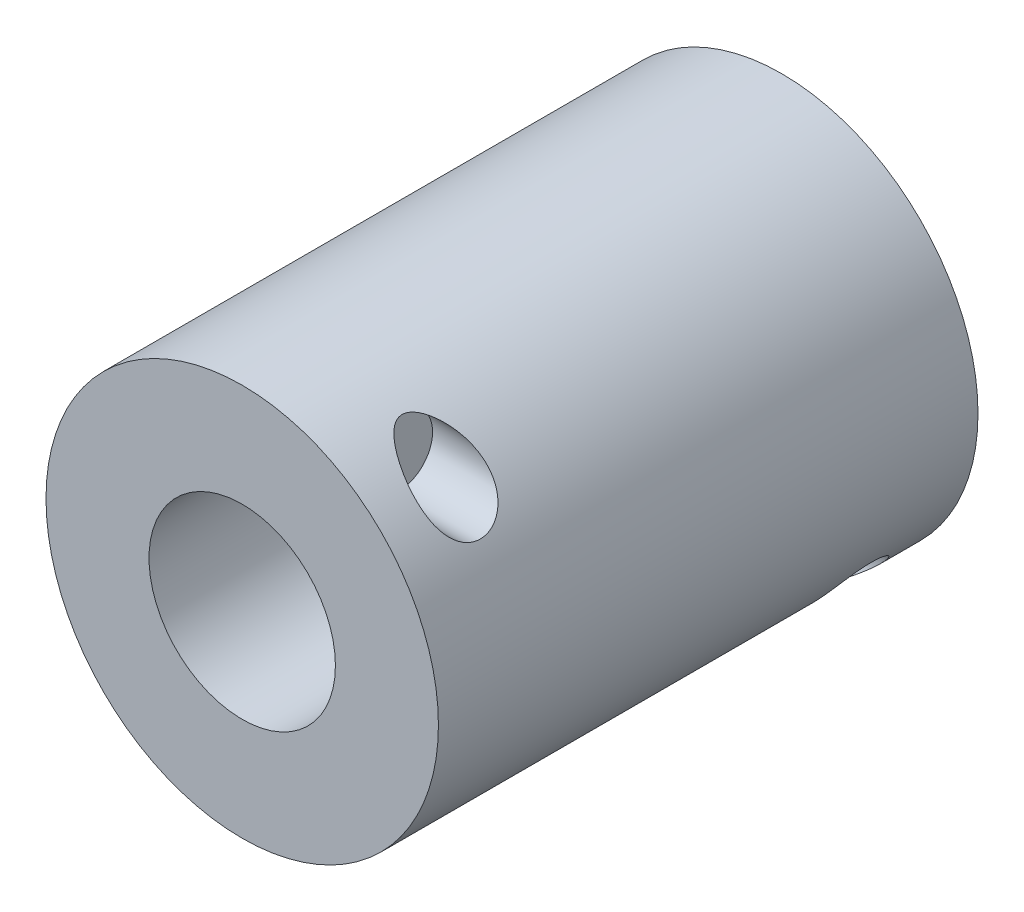
from build123d import *

# Parameters (mm, degrees)
SKETCH1_R           = 20
SKETCH1_R_2         = 9.5
BOSS_EXTRUDE1_DEPTH = 55
SKETCH2_R           = 3.5
CUT_EXTRUDE1_DEPTH  = 12.66666667


with BuildPart() as part:
    # Sketch1 → Boss-Extrude1 (new body)
    with BuildSketch(Plane.XY):
        Circle(SKETCH1_R)
        Circle(SKETCH1_R_2, mode=Mode.SUBTRACT)
    extrude(amount=BOSS_EXTRUDE1_DEPTH)

    # Sketch2 → Cut-Extrude1 (cut, through all)
    with BuildSketch(Plane(origin=(8.33333333, 0, 0), x_dir=(0, 0, -1), z_dir=(1, 0, 0))):
        with Locations((-47.428775099, 14.493654617)):
            Circle(SKETCH2_R)
        with Locations((-7.571224901, -14.493654617)):
            Circle(SKETCH2_R)
    extrude(amount=CUT_EXTRUDE1_DEPTH, mode=Mode.SUBTRACT)


solid = part.part
